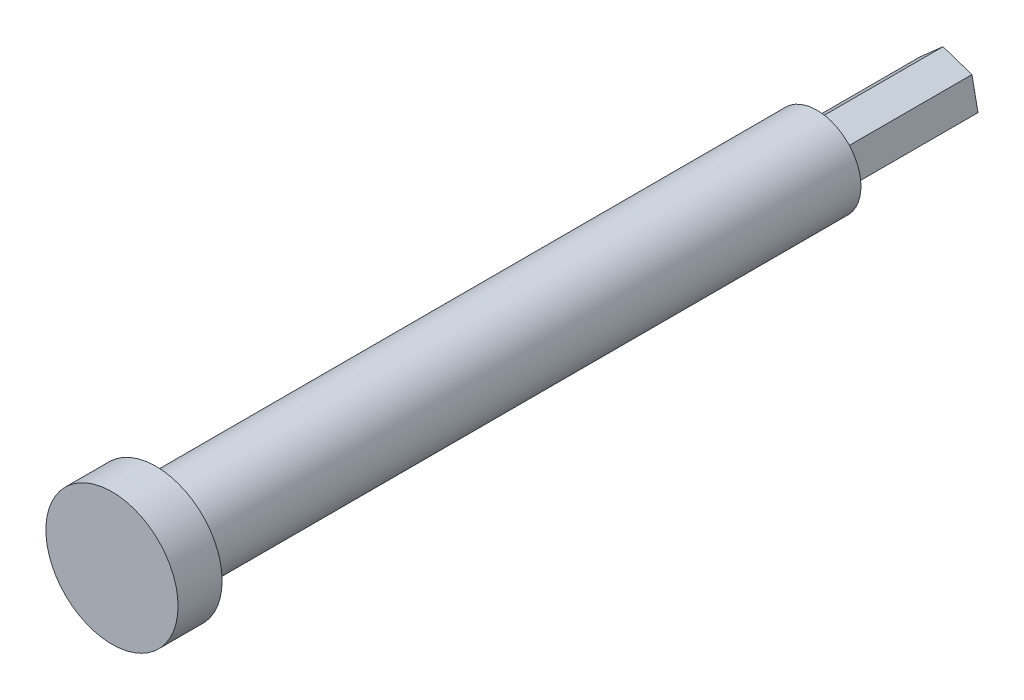
from build123d import *

# Parameters (mm, degrees)
BOSS_EXTRU_1_DEPTH = 15
ESQUISSE2_R        = 5
BOSS_EXTRU_2_DEPTH = 75
ESQUISSE3_R        = 7.5
BOSS_EXTRU_3_DEPTH = 5


with BuildPart() as part:
    # Esquisse1 → Boss.-Extru.1 (new body)
    with BuildSketch(Plane.XY):
        Polygon((-0.686649648, 3.395366293), (-3.283798289, 1.103027108), (-2.597148641, -2.292339185), (0.686649648, -3.395366293), (3.283798289, -1.103027108), (2.597148641, 2.292339185), align=None)
    extrude(amount=BOSS_EXTRU_1_DEPTH)

    # Esquisse2 → Boss.-Extru.2 (add)
    with BuildSketch(Plane.XY.offset(15)):
        Circle(ESQUISSE2_R)
    extrude(amount=BOSS_EXTRU_2_DEPTH)

    # Esquisse3 → Boss.-Extru.3 (add)
    with BuildSketch(Plane.XY.offset(90)):
        Circle(ESQUISSE3_R)
    extrude(amount=BOSS_EXTRU_3_DEPTH)


solid = part.part
